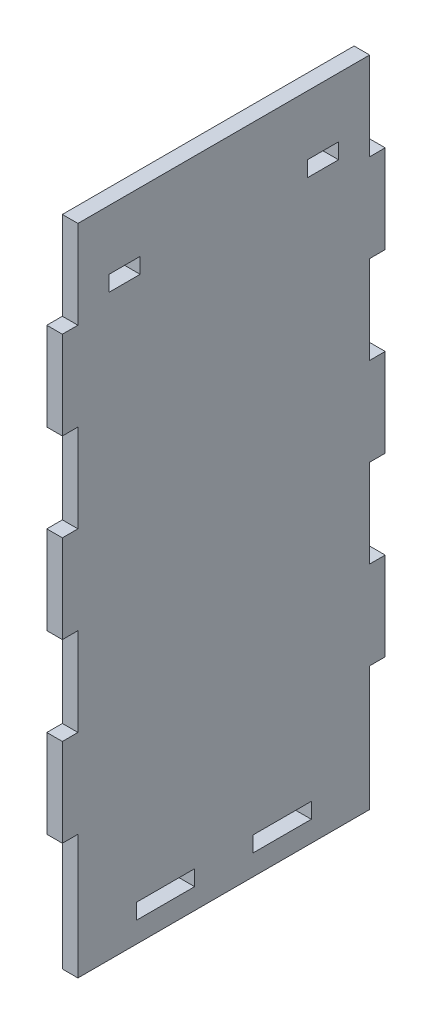
from build123d import *

# Parameters (mm, degrees)
SKETCH1_W           = 112.5
SKETCH1_H           = 238
BOSS_EXTRUDE1_DEPTH = 6
SKETCH4_W           = 6
SKETCH4_H           = 22.5
BOSS_EXTRUDE2_DEPTH = 6
SKETCH5_W           = 6
SKETCH5_H           = 34
BOSS_EXTRUDE3_DEPTH = 6
SKETCH6_W           = 12
SKETCH6_H           = 6
CUT_EXTRUDE1_DEPTH  = 800
SKETCH7_W           = 6
SKETCH7_H           = 112.5
BOSS_EXTRUDE4_DEPTH = 8


with BuildPart() as part:
    # Sketch1 → Boss-Extrude1 (new body)
    with BuildSketch(Plane(origin=(0, 0, 0), x_dir=(0, 0, -1), z_dir=(1, 0, 0))):
        Rectangle(SKETCH1_W, SKETCH1_H)
    extrude(amount=BOSS_EXTRUDE1_DEPTH)

    # Sketch4 → Boss-Extrude2 (add)
    with BuildSketch(Plane.XZ.offset(119)):
        with Locations((3, -45)):
            Rectangle(SKETCH4_W, SKETCH4_H)
        with Locations((3, 0)):
            Rectangle(SKETCH4_W, SKETCH4_H)
        with Locations((3, 45)):
            Rectangle(SKETCH4_W, SKETCH4_H)
    extrude(amount=BOSS_EXTRUDE2_DEPTH)

    # Sketch5 → Boss-Extrude3 (add)
    with BuildSketch(Plane(origin=(0, 0, -56.25), x_dir=(-1, 0, 0), z_dir=(0, 0, -1))):
        with Locations((-3, -68)):
            Rectangle(SKETCH5_W, SKETCH5_H)
        with Locations((-3, 0)):
            Rectangle(SKETCH5_W, SKETCH5_H)
        with Locations((-3, 68)):
            Rectangle(SKETCH5_W, SKETCH5_H)
    boss_extrude3 = extrude(amount=BOSS_EXTRUDE3_DEPTH)

    # Mirror1: Boss-Extrude3 across plane
    add(boss_extrude3.mirror(Plane.XY))

    # Sketch6 → Cut-Extrude1 (cut)
    with BuildSketch(Plane(origin=(6, 0, 0), x_dir=(0, 0, -1), z_dir=(1, 0, 0))):
        with Locations((-38.25, 93)):
            Rectangle(SKETCH6_W, SKETCH6_H)
        with Locations((38.25, 93)):
            Rectangle(SKETCH6_W, SKETCH6_H)
    extrude(amount=-CUT_EXTRUDE1_DEPTH, mode=Mode.SUBTRACT)

    # Sketch7 → Boss-Extrude4 (add)
    with BuildSketch(Plane.XZ.offset(125)):
        with Locations((3, 0)):
            Rectangle(SKETCH7_W, SKETCH7_H)
    extrude(amount=BOSS_EXTRUDE4_DEPTH)


solid = part.part
